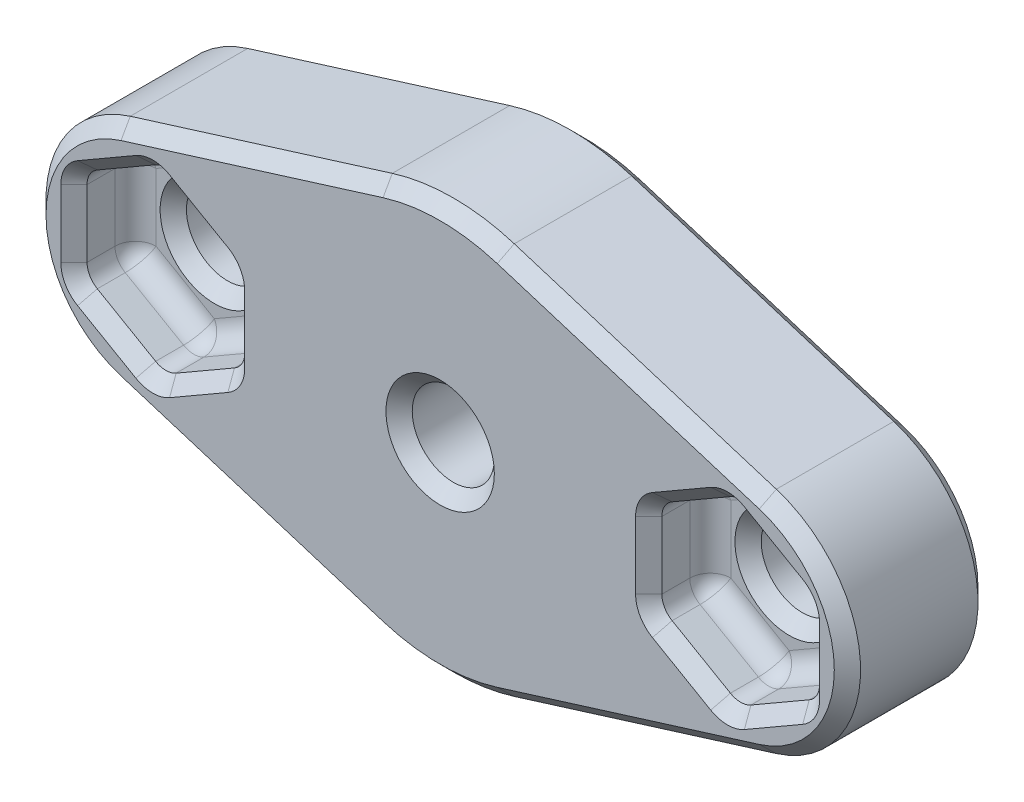
from build123d import *

# Parameters (mm, degrees)
SKETCH10_R          = 1.5875
BOSS_EXTRUDE2_DEPTH = 5.55625
CUT_EXTRUDE5_DEPTH  = 2.38125
CUT_EXTRUDE6_DEPTH  = 2.38125
FILLET2_R           = 0.79375
CHAMFER2_SIZE       = 0.508


with BuildPart() as part:
    # Sketch10 → Boss-Extrude2 (new body)
    with BuildSketch(Plane.XY):
        with BuildLine():
            Line((-12.489905714, 4.426128528), (-2.358571429, 7.578987206))
            ThreePointArc((-2.358571429, 7.578987206), (0, 7.9375), (2.358571429, 7.578987206))
            Line((2.358571429, 7.578987206), (12.489905714, 4.426128528))
            ThreePointArc((12.489905714, 4.426128528), (15.748, 0), (12.489905714, -4.426128528))
            Line((12.489905714, -4.426128528), (2.358571429, -7.578987206))
            ThreePointArc((2.358571429, -7.578987206), (0, -7.9375), (-2.358571429, -7.578987206))
            Line((-2.358571429, -7.578987206), (-12.489905714, -4.426128528))
            ThreePointArc((-12.489905714, -4.426128528), (-15.748, 0), (-12.489905714, 4.426128528))
        make_face()
        Circle(SKETCH10_R, mode=Mode.SUBTRACT)
        with Locations((-11.1125, 0)):
            Circle(SKETCH10_R, mode=Mode.SUBTRACT)
        with Locations((11.1125, 0)):
            Circle(SKETCH10_R, mode=Mode.SUBTRACT)
    extrude(amount=BOSS_EXTRUDE2_DEPTH)

    # Sketch11 → Cut-Extrude5 (cut)
    with BuildSketch(Plane.XY.offset(5.55625)):
        Polygon((-11.1125, 3.519527241), (-14.1605, 1.75976362), (-14.1605, -1.75976362), (-11.1125, -3.519527241), (-8.0645, -1.75976362), (-8.0645, 1.75976362), align=None)
        Polygon((14.1605, 1.75976362), (11.1125, 3.519527241), (8.0645, 1.75976362), (8.0645, -1.75976362), (11.1125, -3.519527241), (14.1605, -1.75976362), align=None)
    extrude(amount=-CUT_EXTRUDE5_DEPTH, mode=Mode.SUBTRACT)

    # Sketch12 → Cut-Extrude6 (cut)
    with BuildSketch(Plane(origin=(0, 0, 0), x_dir=(-1, 0, 0), z_dir=(0, 0, -1))):
        Polygon((3.048, 1.75976362), (0, 3.519527241), (-3.048, 1.75976362), (-3.048, -1.75976362), (0, -3.519527241), (3.048, -1.75976362), align=None)
    extrude(amount=-CUT_EXTRUDE6_DEPTH, mode=Mode.SUBTRACT)

    # Fillet2
    fillet2_edges = [part.edges().sort_by_distance(p)[0] for p in [
        (-9.5885, 2.639645431, 3.175),
        (-11.1125, 3.519527241, 4.365625),
        (-8.0645, 0, 3.175),
        (-8.0645, 1.75976362, 4.365625),
        (-9.5885, -2.639645431, 3.175),
        (-8.0645, -1.75976362, 4.365625),
        (-12.6365, -2.639645431, 3.175),
        (-11.1125, -3.519527241, 4.365625),
        (-14.1605, 0, 3.175),
        (-14.1605, -1.75976362, 4.365625),
        (-12.6365, 2.639645431, 3.175),
        (-14.1605, 1.75976362, 4.365625),
        (14.1605, 0, 3.175),
        (14.1605, 1.75976362, 4.365625),
        (12.6365, -2.639645431, 3.175),
        (14.1605, -1.75976362, 4.365625),
        (9.5885, -2.639645431, 3.175),
        (11.1125, -3.519527241, 4.365625),
        (8.0645, 0, 3.175),
        (8.0645, -1.75976362, 4.365625),
        (9.5885, 2.639645431, 3.175),
        (8.0645, 1.75976362, 4.365625),
        (12.6365, 2.639645431, 3.175),
        (11.1125, 3.519527241, 4.365625),
        (-3.048, 0, 2.38125),
        (-3.048, 1.75976362, 1.190625),
        (-1.524, -2.639645431, 2.38125),
        (-3.048, -1.75976362, 1.190625),
        (1.524, -2.639645431, 2.38125),
        (0, -3.519527241, 1.190625),
        (3.048, 0, 2.38125),
        (3.048, -1.75976362, 1.190625),
        (1.524, 2.639645431, 2.38125),
        (3.048, 1.75976362, 1.190625),
        (-1.524, 2.639645431, 2.38125),
        (0, 3.519527241, 1.190625),
    ]]
    fillet(fillet2_edges, radius=FILLET2_R)

    # Chamfer2
    chamfer2_edges = [part.edges().sort_by_distance(p)[0] for p in [
        (7.424238571, -6.002557867, 0),
        (0, -7.9375, 0),
        (-1.524, 2.639645431, 0),
        (1.524, 2.639645431, 0),
        (-7.424238571, -6.002557867, 0),
        (3.048, 0, 0),
        (1.524, -2.639645431, 0),
        (-15.748, 0, 0),
        (-1.524, -2.639645431, 0),
        (-3.048, 0, 0),
        (14.1605, 0, 5.55625),
        (12.6365, 2.639645431, 5.55625),
        (9.5885, 2.639645431, 5.55625),
        (8.0645, 0, 5.55625),
        (0, -7.9375, 5.55625),
        (9.5885, -2.639645431, 5.55625),
        (12.6365, -2.639645431, 5.55625),
        (-9.5885, 2.639645431, 5.55625),
        (-12.6365, 2.639645431, 5.55625),
        (-14.1605, 0, 5.55625),
        (-12.6365, -2.639645431, 5.55625),
        (-9.5885, -2.639645431, 5.55625),
        (-8.0645, 0, 5.55625),
        (-2.941657664, 1.698366844, 0),
        (0, 3.396733689, 0),
        (2.941657664, 1.698366844, 0),
        (2.941657664, -1.698366844, 0),
        (0, -3.396733689, 0),
        (-2.941657664, -1.698366844, 0),
        (14.054157664, 1.698366844, 5.55625),
        (11.1125, 3.396733689, 5.55625),
        (8.170842336, 1.698366844, 5.55625),
        (8.170842336, -1.698366844, 5.55625),
        (11.1125, -3.396733689, 5.55625),
        (14.054157664, -1.698366844, 5.55625),
        (-11.1125, 3.396733689, 5.55625),
        (-14.054157664, 1.698366844, 5.55625),
        (-11.1125, -3.396733689, 5.55625),
        (-8.170842336, -1.698366844, 5.55625),
        (-8.170842336, 1.698366844, 5.55625),
        (-14.054157664, -1.698366844, 5.55625),
        (7.424238571, -6.002557867, 5.55625),
        (15.748, 0, 5.55625),
        (-1.5875, 0, 5.55625),
        (7.424238571, 6.002557867, 5.55625),
        (-12.7, 0, 0),
        (0, 7.9375, 5.55625),
        (9.525, 0, 0),
        (-7.424238571, 6.002557867, 5.55625),
        (-12.7, 0, 3.175),
        (-15.748, 0, 5.55625),
        (9.525, 0, 3.175),
        (-1.5875, 0, 2.38125),
        (-7.424238571, 6.002557867, 0),
        (-7.424238571, -6.002557867, 5.55625),
        (0, 7.9375, 0),
        (7.424238571, 6.002557867, 0),
        (15.748, 0, 0),
    ]]
    chamfer(chamfer2_edges, length=CHAMFER2_SIZE)


solid = part.part
